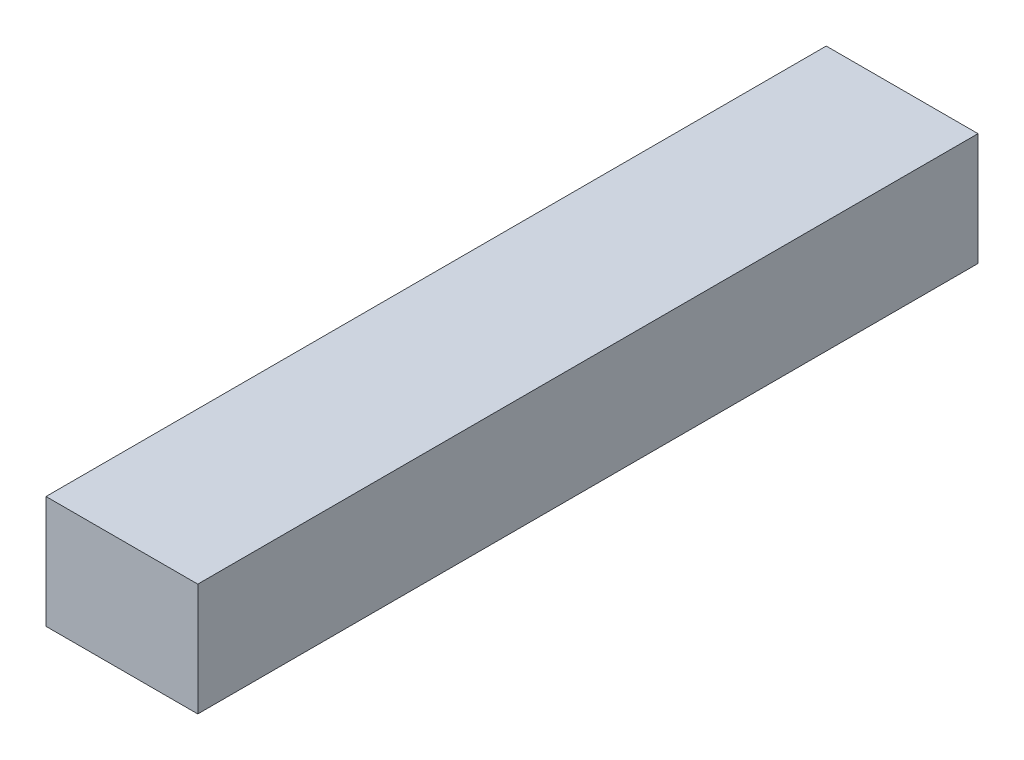
from build123d import *

# Parameters (mm, degrees)
ESQUISSE1_W        = 7.8
ESQUISSE1_H        = 5.78
BOSS_EXTRU_1_DEPTH = 40.1


with BuildPart() as part:
    # Esquisse1 → Boss.-Extru.1 (new body)
    with BuildSketch(Plane.XY):
        Rectangle(ESQUISSE1_W, ESQUISSE1_H)
    extrude(amount=BOSS_EXTRU_1_DEPTH)


solid = part.part
